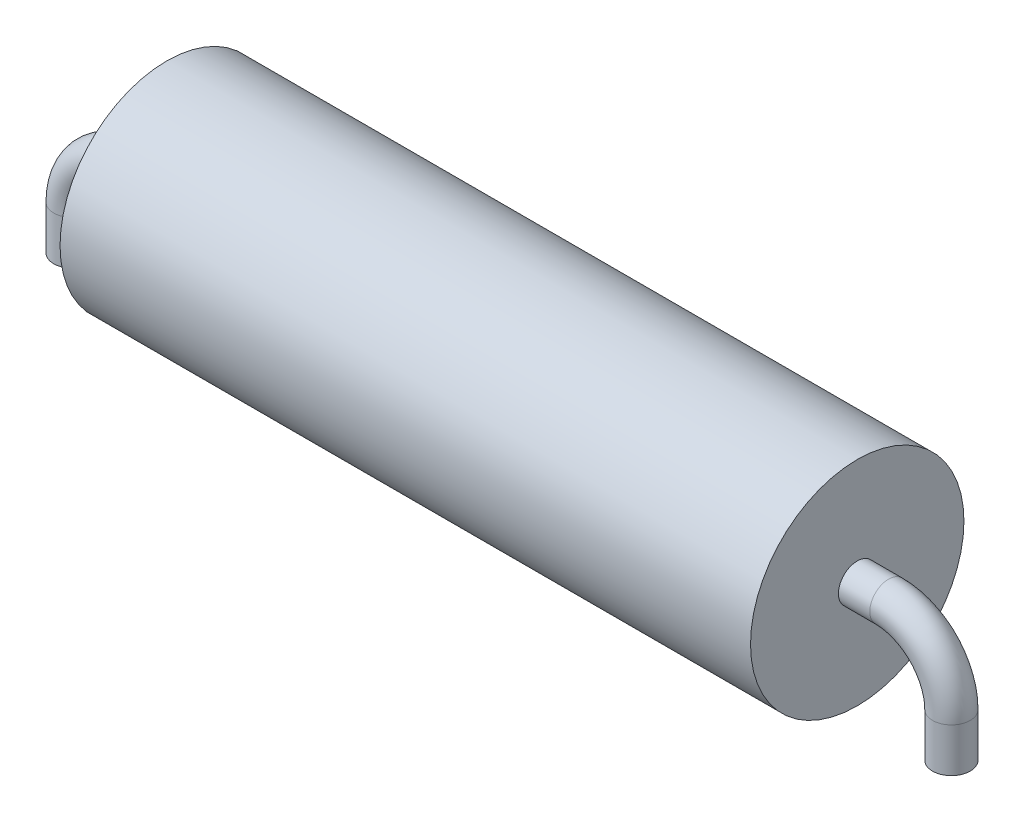
from build123d import *

# Parameters (mm, degrees)
BOSS_EXTRUDE1_DEPTH      = 5.5
BOSS_EXTRUDE1_DEPTH_BACK = 5.5
SKETCH1_R                = 1.7
SWEEP1_PROFILE_R         = 0.3


with BuildPart() as part:
    # Sketch1 → Boss-Extrude1 (new, two sides: drawn at the far end of the back side and taken through both)
    with BuildSketch(Plane(origin=(0, 0, 0), x_dir=(0, 0, -1), z_dir=(1, 0, 0)).offset(-BOSS_EXTRUDE1_DEPTH_BACK)):
        Circle(SKETCH1_R)
    extrude(amount=BOSS_EXTRUDE1_DEPTH + BOSS_EXTRUDE1_DEPTH_BACK)

    # Sweep1: sweep along a path in Sketch2
    with BuildLine(Plane.XY) as sweep1_path:
        Line((-5.5, 0), (-6, 0))
        ThreePointArc((-6, 0), (-6.707106781, -0.292893219), (-7, -1))
        Line((-7, -1), (-7, -1.7))
    # Sweep1 profile (on start of the path) → Sweep1 (sweep)
    with BuildSketch(Plane(origin=(-5.5, 0, 0), x_dir=(0, -1, 0), z_dir=(-1, 0, 0))):
        Circle(SWEEP1_PROFILE_R)
    sweep1 = sweep(path=sweep1_path.line)

    # Mirror1: Sweep1 across plane
    add(sweep1.mirror(Plane(origin=(0, 0, 0), x_dir=(0, 0, 1), z_dir=(1, 0, 0))))


solid = part.part
